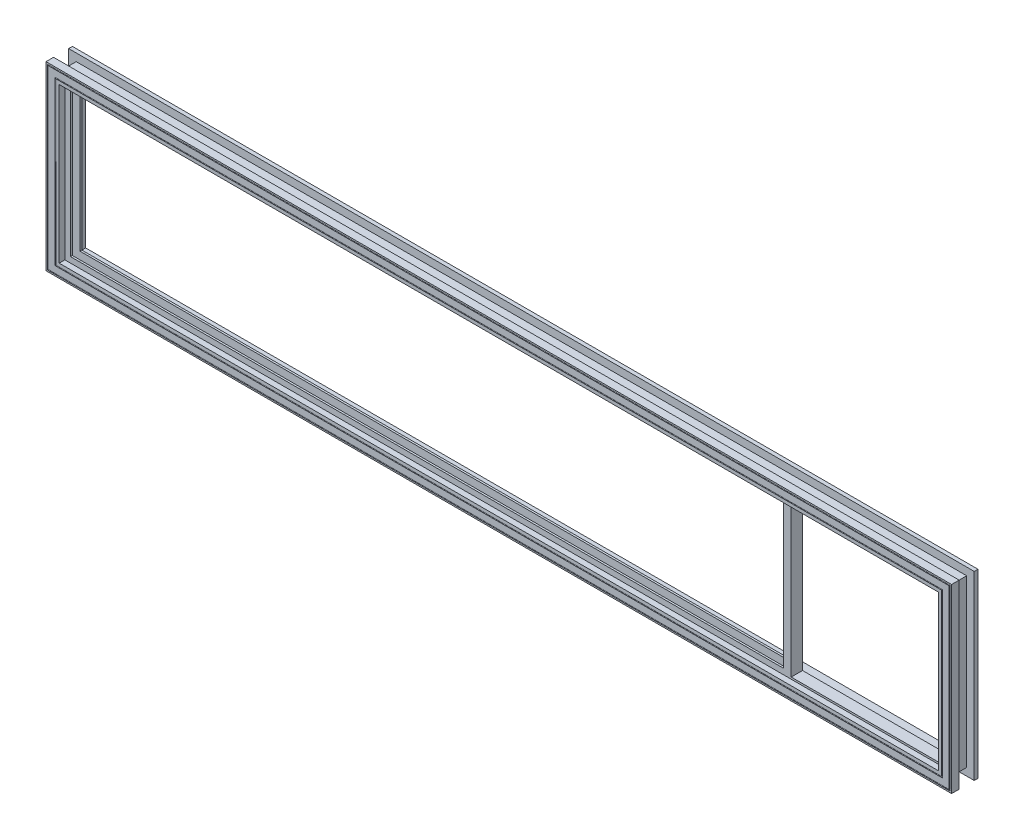
from build123d import *

# Parameters (mm, degrees)
CUT_EXTRUDE1_START  = -19.05
SKETCH3_W           = 254
SKETCH3_H           = 254
CUT_EXTRUDE1_DEPTH  = 19.05
BOSS_EXTRUDE1_DEPTH = 266.7
SKETCH7_W           = 12.7
SKETCH7_H           = 3.175


with BuildPart() as part:
    # Sweep1: sweep along a path in Sketch2
    with BuildLine(Plane.XY) as sweep1_path:
        Line((762, 152.4), (-762, 152.4))
        Line((-762, 152.4), (-762, -152.4))
        Line((-762, -152.4), (762, -152.4))
        Line((762, -152.4), (762, 152.4))
    # Sketch1 → Sweep1 (sweep)
    with BuildSketch(Plane(origin=(0, 0, 0), x_dir=(1, 0, 0), z_dir=(0, 1, 0))):
        with BuildLine():
            Line((-762, -25.4), (-759.587, -25.4))
            ThreePointArc((-759.587, -25.4), (-758.825, -24.638), (-758.063, -25.4))
            Line((-758.063, -25.4), (-746.887, -25.4))
            ThreePointArc((-746.887, -25.4), (-746.125, -24.638), (-745.363, -25.4))
            Line((-745.363, -25.4), (-739.775, -25.4))
            Line((-739.775, -25.4), (-739.775, -15.875))
            Line((-739.775, -15.875), (-730.25, -15.875))
            Line((-730.25, -15.875), (-730.25, -12.7))
            Line((-730.25, -12.7), (-742.95, -12.7))
            Line((-742.95, -12.7), (-742.95, 0))
            Line((-742.95, 0), (-730.25, 0))
            Line((-730.25, 0), (-730.25, 3.175))
            Line((-730.25, 3.175), (-739.775, 3.175))
            Line((-739.775, 3.175), (-739.775, 19.05))
            Line((-739.775, 19.05), (-745.744, 19.05))
            ThreePointArc((-745.744, 19.05), (-746.125, 18.669), (-746.506, 19.05))
            Line((-746.506, 19.05), (-758.444, 19.05))
            ThreePointArc((-758.444, 19.05), (-758.825, 18.669), (-759.206, 19.05))
            Line((-759.206, 19.05), (-762, 19.05))
            Line((-762, 19.05), (-762, 12.7))
            Line((-762, 12.7), (-749.3, 12.7))
            Line((-749.3, 12.7), (-749.3, -12.7))
            Line((-749.3, -12.7), (-762, -12.7))
            Line((-762, -12.7), (-762, -25.4))
        make_face()
    sweep(path=sweep1_path.line, transition=Transition.RIGHT)

    # Sketch3 → Cut-Extrude1 (cut)
    with BuildSketch(Plane.XY.offset(15.875).offset(CUT_EXTRUDE1_START)):
        with Locations((609.6, 0)):
            Rectangle(SKETCH3_W, SKETCH3_H)
    extrude(amount=CUT_EXTRUDE1_DEPTH, mode=Mode.SUBTRACT)

    # Sketch6 → Boss-Extrude1 (add)
    with BuildSketch(Plane(origin=(0, -133.35, 0), x_dir=(1, 0, 0), z_dir=(0, 1, 0))):
        Polygon((482.6, 3.175), (482.6, -15.875), (469.9, -15.875), (469.9, -12.7), (479.425, -12.7), (479.425, 0), (469.9, 0), (469.9, 3.175), align=None)
    extrude(amount=BOSS_EXTRUDE1_DEPTH)

    # Sweep2: sweep along a path in Sketch8
    with BuildLine(Plane(origin=(0, 0, -3.175), x_dir=(-1, 0, 0), z_dir=(0, 0, -1))) as sweep2_path:
        Line((-482.6, -127), (-736.6, -127))
        Line((-736.6, -127), (-736.6, 127))
        Line((-736.6, 127), (-482.6, 127))
    # Sketch7 → Sweep2 (sweep)
    with BuildSketch(Plane(origin=(482.6, 0, 0), x_dir=(0, 0, -1), z_dir=(1, 0, 0))):
        with Locations((-6.35, -128.5875)):
            Rectangle(SKETCH7_W, SKETCH7_H)
    sweep(path=sweep2_path.line, transition=Transition.RIGHT)


solid = part.part
